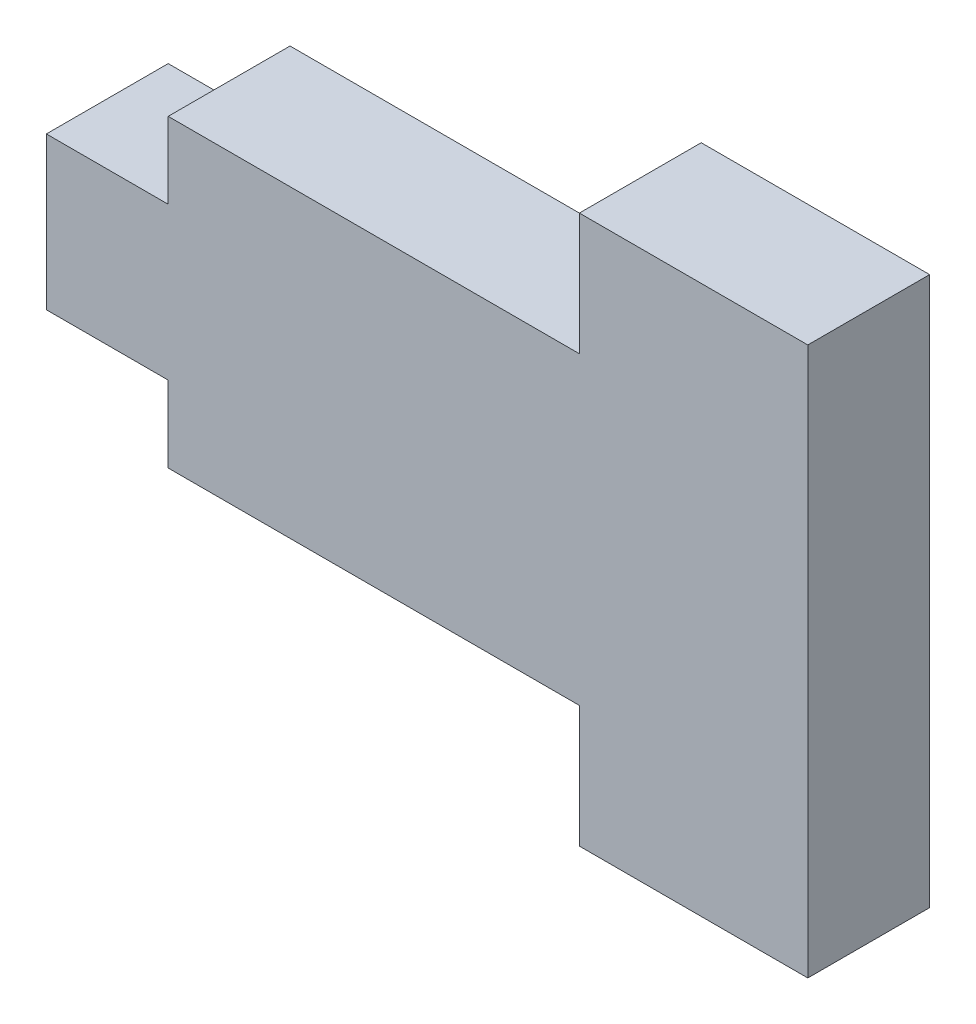
from build123d import *

# Parameters (mm, degrees)
SKETCH1_W           = 5.08
SKETCH1_H           = 6.35
SKETCH1_W_2         = 26.67
SKETCH1_H_2         = 12.7
SKETCH1_W_3         = 9.525
SKETCH1_H_3         = 5.08
BOSS_EXTRUDE1_DEPTH = 5.08


with BuildPart() as part:
    # Sketch1 → Boss-Extrude1 (new body)
    with BuildSketch(Plane.XY):
        with Locations((-15.875, 0)):
            Rectangle(SKETCH1_W, SKETCH1_H)
        Rectangle(SKETCH1_W_2, SKETCH1_H_2)
        with Locations((8.5725, 8.89)):
            Rectangle(SKETCH1_W_3, SKETCH1_H_3)
        with Locations((8.5725, -8.89)):
            Rectangle(SKETCH1_W_3, SKETCH1_H_3)
    extrude(amount=BOSS_EXTRUDE1_DEPTH)


solid = part.part
